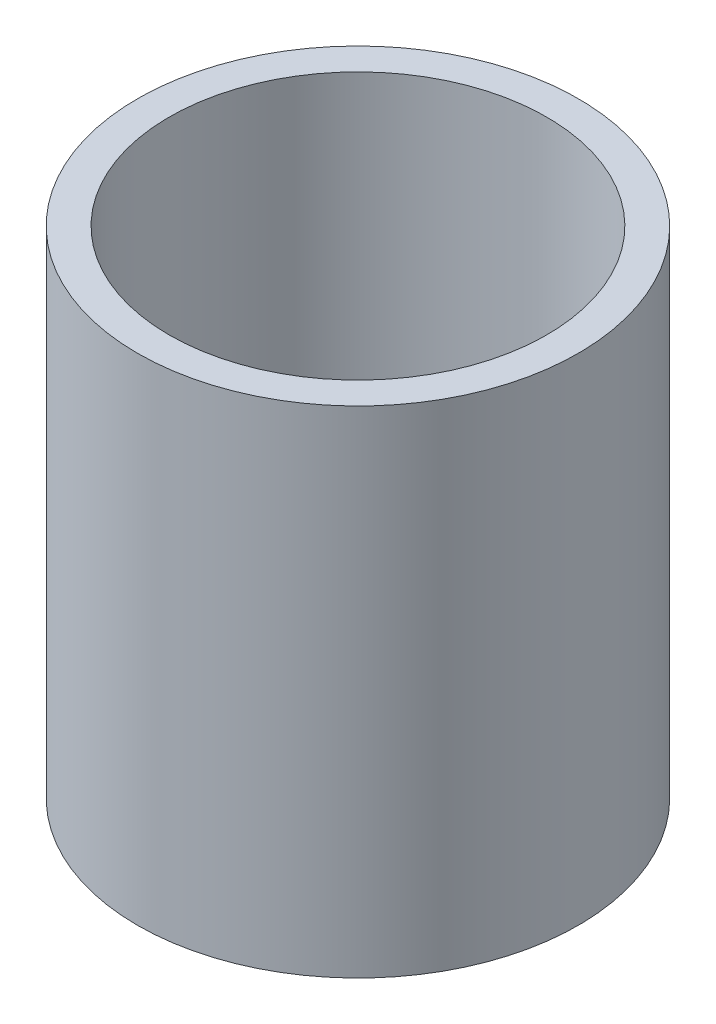
from build123d import *

# Parameters (mm, degrees)
SKETCH1_R           = 44.5
SKETCH1_R_2         = 41.6
SKETCH1_R_3         = 38.1
BOSS_EXTRUDE1_DEPTH = 100


with BuildPart() as part:
    # Sketch1 → Boss-Extrude1 (new body)
    with BuildSketch(Plane(origin=(0, 0, 0), x_dir=(1, 0, 0), z_dir=(0, 1, 0))):
        Circle(SKETCH1_R)
        Circle(SKETCH1_R_2, mode=Mode.SUBTRACT)
        Circle(SKETCH1_R_2)
        Circle(SKETCH1_R_3, mode=Mode.SUBTRACT)
    extrude(amount=-BOSS_EXTRUDE1_DEPTH)


solid = part.part
